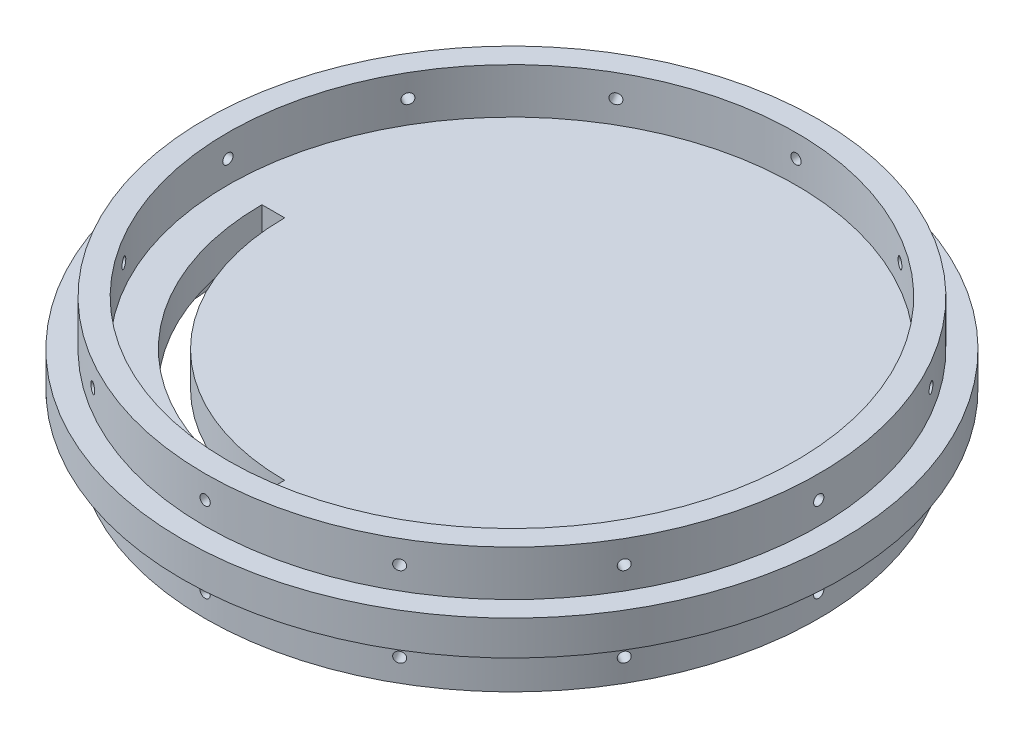
from build123d import *

# Parameters (mm, degrees)
SKETCH1_R                = 92.075
BOSS_EXTRUDE1_DEPTH      = 4.826
SKETCH4_R                = 85.725
SKETCH4_R_2              = 79.375
BOSS_EXTRUDE2_DEPTH      = 12.7
SKETCH5_R                = 1.4351
CUT_EXTRUDE2_DEPTH       = 12.7
CIRPATTERN1_COUNT        = 12
MIRROR2_COPY_1_SKETCH_R  = 1.4351
MIRROR2_COPY_1_DEPTH     = 12.7
MIRROR2_COPY_2_SKETCH_R  = 1.4351
MIRROR2_COPY_2_DEPTH     = 12.7
MIRROR2_COPY_3_SKETCH_R  = 1.4351
MIRROR2_COPY_3_DEPTH     = 12.7
MIRROR2_COPY_4_SKETCH_R  = 1.4351
MIRROR2_COPY_4_DEPTH     = 12.7
MIRROR2_COPY_5_SKETCH_R  = 1.4351
MIRROR2_COPY_5_DEPTH     = 12.7
MIRROR2_COPY_6_SKETCH_R  = 1.4351
MIRROR2_COPY_6_DEPTH     = 12.7
MIRROR2_COPY_7_SKETCH_R  = 1.4351
MIRROR2_COPY_7_DEPTH     = 12.7
MIRROR2_COPY_8_SKETCH_R  = 1.4351
MIRROR2_COPY_8_DEPTH     = 12.7
MIRROR2_COPY_9_SKETCH_R  = 1.4351
MIRROR2_COPY_9_DEPTH     = 12.7
MIRROR2_COPY_10_SKETCH_R = 1.4351
MIRROR2_COPY_10_DEPTH    = 12.7
MIRROR2_COPY_11_SKETCH_R = 1.4351
MIRROR2_COPY_11_DEPTH    = 12.7
CUT_EXTRUDE3_DEPTH       = 9.652


with BuildPart() as part:
    # Sketch1 → Boss-Extrude1 (new, symmetric)
    with BuildSketch(Plane(origin=(0, 0, 0), x_dir=(1, 0, 0), z_dir=(0, 1, 0))):
        with Locations(Location((0, 0, 0), (0, 0, 270))):
            Circle(SKETCH1_R)
    extrude(amount=BOSS_EXTRUDE1_DEPTH, both=True)

    # Sketch2 → Cut-Revolve1 (revolve, cut)
    with BuildSketch(Plane.XY, mode=Mode.PRIVATE) as cut_revolve1_sk:
        with BuildLine():
            Line((0, -4.826), (-19.2970404, -4.826))
            ThreePointArc((-19.2970404, -4.826), (-9.985310315, -2.33207385), (-0.381787908, -1.495209354))
            Line((-0.381787908, -1.495209354), (0, -1.495209354))
            Line((0, -1.495209354), (0, -4.826))
        make_face()
    revolve(cut_revolve1_sk.sketch.rotate(Axis((0, -18.327530441, 0), (0, 1, 0)), 270), axis=Axis((0, -18.327530441, 0), (0, 1, 0)), mode=Mode.SUBTRACT)

    # Sketch4 → Boss-Extrude2 (add)
    with BuildSketch(Plane(origin=(0, 4.826, 0), x_dir=(1, 0, 0), z_dir=(0, 1, 0))):
        with Locations(Location((0, 0, 0), (0, 0, 270))):
            Circle(SKETCH4_R)
        with Locations(Location((0, 0, 0), (0, 0, 270))):
            Circle(SKETCH4_R_2, mode=Mode.SUBTRACT)
    boss_extrude2 = extrude(amount=BOSS_EXTRUDE2_DEPTH)

    # Sketch5 → Cut-Extrude2 (cut)
    with BuildSketch(Plane(origin=(0, 0, -85.725), x_dir=(-1, 0, 0), z_dir=(0, 0, -1))):
        with Locations(Location((0, 11.176, 0), (0, 0, 90))):
            Circle(SKETCH5_R)
    cut_extrude2 = extrude(amount=-CUT_EXTRUDE2_DEPTH, mode=Mode.SUBTRACT)

    # CirPattern1: Cut-Extrude2 ×12 about axis
    cirpattern1_axis = Axis((0, 17.526, 0), (0, -1, 0))
    for i in range(1, CIRPATTERN1_COUNT):
        add(cut_extrude2.rotate(cirpattern1_axis, i * 360 / CIRPATTERN1_COUNT), mode=Mode.SUBTRACT)

    # Mirror2: Boss-Extrude2, Cut-Extrude2 across plane
    add(boss_extrude2.mirror(Plane.ZX))
    add(cut_extrude2.mirror(Plane.ZX), mode=Mode.SUBTRACT)

    # Mirror2 copy 1 sketch → Mirror2 copy 1 (cut)
    with BuildSketch(Plane(origin=(42.8625, 0, -74.240027739), x_dir=(-0.8660254037844387, 0, -0.49999999999999994), z_dir=(0.49999999999999994, 0, -0.8660254037844387))):
        with Locations((0, -11.176)):
            Circle(MIRROR2_COPY_1_SKETCH_R)
    extrude(amount=-MIRROR2_COPY_1_DEPTH, mode=Mode.SUBTRACT)

    # Mirror2 copy 2 sketch → Mirror2 copy 2 (cut)
    with BuildSketch(Plane(origin=(74.240027739, 0, -42.8625), x_dir=(-0.5000000000000001, 0, -0.8660254037844386), z_dir=(0.8660254037844386, 0, -0.5000000000000001))):
        with Locations((0, -11.176)):
            Circle(MIRROR2_COPY_2_SKETCH_R)
    extrude(amount=-MIRROR2_COPY_2_DEPTH, mode=Mode.SUBTRACT)

    # Mirror2 copy 3 sketch → Mirror2 copy 3 (cut)
    with BuildSketch(Plane(origin=(85.725, 0, 0), x_dir=(0, 0, -1), z_dir=(1, 0, 0))):
        with Locations((0, -11.176)):
            Circle(MIRROR2_COPY_3_SKETCH_R)
    extrude(amount=-MIRROR2_COPY_3_DEPTH, mode=Mode.SUBTRACT)

    # Mirror2 copy 4 sketch → Mirror2 copy 4 (cut)
    with BuildSketch(Plane(origin=(74.240027739, 0, 42.8625), x_dir=(0.4999999999999998, 0, -0.8660254037844387), z_dir=(0.8660254037844387, 0, 0.4999999999999998))):
        with Locations((0, -11.176)):
            Circle(MIRROR2_COPY_4_SKETCH_R)
    extrude(amount=-MIRROR2_COPY_4_DEPTH, mode=Mode.SUBTRACT)

    # Mirror2 copy 5 sketch → Mirror2 copy 5 (cut)
    with BuildSketch(Plane(origin=(42.8625, 0, 74.240027739), x_dir=(0.8660254037844387, 0, -0.49999999999999994), z_dir=(0.49999999999999994, 0, 0.8660254037844387))):
        with Locations((0, -11.176)):
            Circle(MIRROR2_COPY_5_SKETCH_R)
    extrude(amount=-MIRROR2_COPY_5_DEPTH, mode=Mode.SUBTRACT)

    # Mirror2 copy 6 sketch → Mirror2 copy 6 (cut)
    with BuildSketch(Plane.XY.offset(85.725)):
        with Locations((0, -11.176)):
            Circle(MIRROR2_COPY_6_SKETCH_R)
    extrude(amount=-MIRROR2_COPY_6_DEPTH, mode=Mode.SUBTRACT)

    # Mirror2 copy 7 sketch → Mirror2 copy 7 (cut)
    with BuildSketch(Plane(origin=(-42.8625, 0, 74.240027739), x_dir=(0.8660254037844386, 0, 0.5000000000000001), z_dir=(-0.5000000000000001, 0, 0.8660254037844386))):
        with Locations((0, -11.176)):
            Circle(MIRROR2_COPY_7_SKETCH_R)
    extrude(amount=-MIRROR2_COPY_7_DEPTH, mode=Mode.SUBTRACT)

    # Mirror2 copy 8 sketch → Mirror2 copy 8 (cut)
    with BuildSketch(Plane(origin=(-74.240027739, 0, 42.8625), x_dir=(0.5000000000000004, 0, 0.8660254037844384), z_dir=(-0.8660254037844384, 0, 0.5000000000000004))):
        with Locations((0, -11.176)):
            Circle(MIRROR2_COPY_8_SKETCH_R)
    extrude(amount=-MIRROR2_COPY_8_DEPTH, mode=Mode.SUBTRACT)

    # Mirror2 copy 9 sketch → Mirror2 copy 9 (cut)
    with BuildSketch(Plane.ZY.offset(85.725)):
        with Locations((0, -11.176)):
            Circle(MIRROR2_COPY_9_SKETCH_R)
    extrude(amount=-MIRROR2_COPY_9_DEPTH, mode=Mode.SUBTRACT)

    # Mirror2 copy 10 sketch → Mirror2 copy 10 (cut)
    with BuildSketch(Plane(origin=(-74.240027739, 0, -42.8625), x_dir=(-0.5000000000000001, 0, 0.8660254037844386), z_dir=(-0.8660254037844386, 0, -0.5000000000000001))):
        with Locations((0, -11.176)):
            Circle(MIRROR2_COPY_10_SKETCH_R)
    extrude(amount=-MIRROR2_COPY_10_DEPTH, mode=Mode.SUBTRACT)

    # Mirror2 copy 11 sketch → Mirror2 copy 11 (cut)
    with BuildSketch(Plane(origin=(-42.8625, 0, -74.240027739), x_dir=(-0.8660254037844384, 0, 0.5000000000000004), z_dir=(-0.5000000000000004, 0, -0.8660254037844384))):
        with Locations((0, -11.176)):
            Circle(MIRROR2_COPY_11_SKETCH_R)
    extrude(amount=-MIRROR2_COPY_11_DEPTH, mode=Mode.SUBTRACT)

    # Sketch6 → Cut-Extrude3 (cut)
    with BuildSketch(Plane(origin=(0, 4.826, 0), x_dir=(1, 0, 0), z_dir=(0, 1, 0))):
        with BuildLine():
            Line((-63.5, 0), (-69.85, 0))
            ThreePointArc((-69.85, 0), (-49.391408666, -49.391408666), (0, -69.85))
            Line((0, -69.85), (0, -63.5))
            ThreePointArc((0, -63.5), (-44.901280605, -44.901280605), (-63.5, 0))
        make_face()
    extrude(amount=-CUT_EXTRUDE3_DEPTH, mode=Mode.SUBTRACT)


solid = part.part
